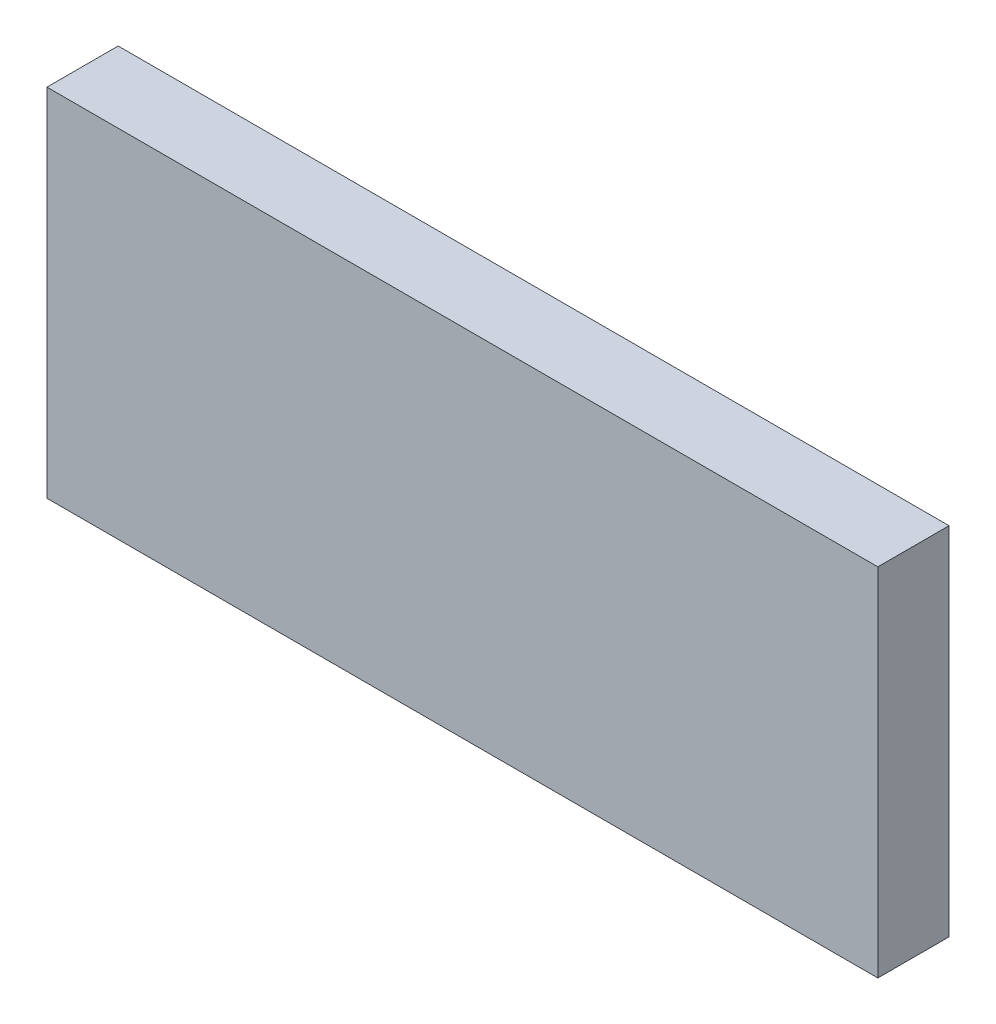
from build123d import *

# Parameters (mm, degrees)
CROQUIS1_W              = 35
CROQUIS1_H              = 15
SALIENTE_EXTRUIR1_DEPTH = 3


with BuildPart() as part:
    # Croquis1 → Saliente-Extruir1 (new body)
    with BuildSketch(Plane.XY):
        Rectangle(CROQUIS1_W, CROQUIS1_H)
    extrude(amount=SALIENTE_EXTRUIR1_DEPTH)


solid = part.part
